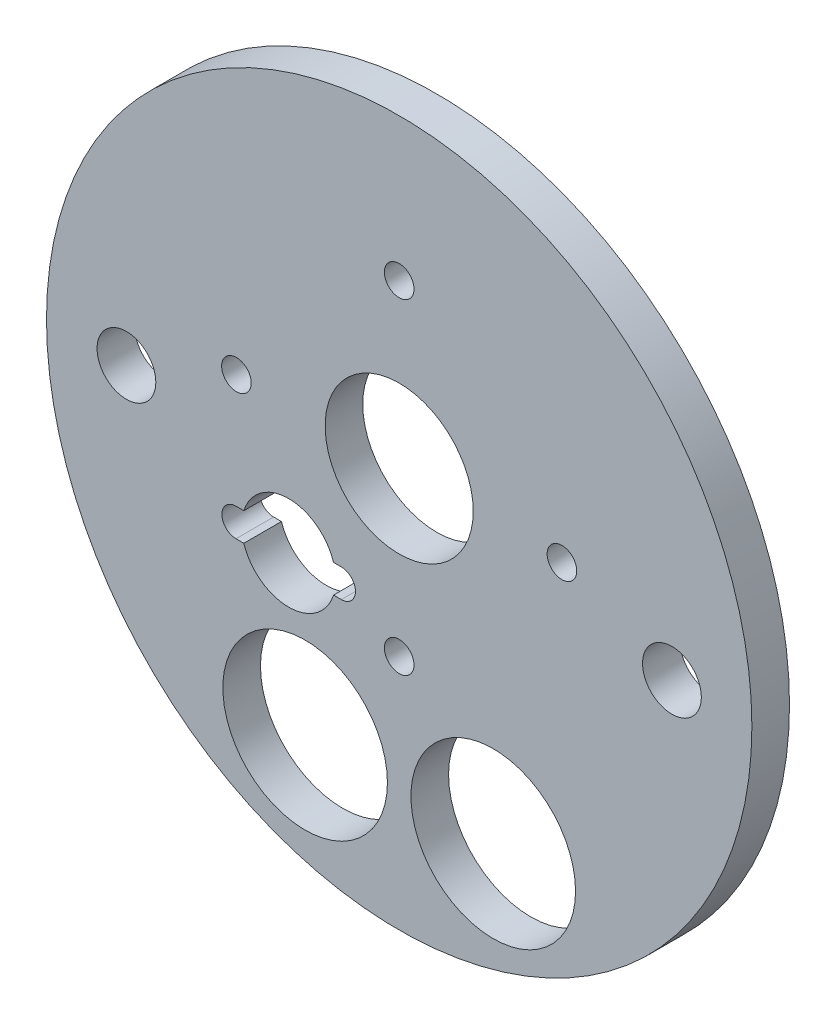
from build123d import *

# Parameters (mm, degrees)
SKETCH1_R           = 49.5046
BOSS_EXTRUDE1_DEPTH = 5.08
SKETCH2_R           = 47.625
BOSS_EXTRUDE2_DEPTH = 5.08
SKETCH3_R           = 11.1125
SKETCH3_R_2         = 3.96875
SKETCH3_R_3         = 10
SKETCH3_R_4         = 2
CUT_EXTRUDE1_DEPTH  = 11.16
SKETCH7_R           = 52.166274697
CUT_EXTRUDE4_DEPTH  = 5.08


with BuildPart() as part:
    # Sketch1 → Boss-Extrude1 (new body)
    with BuildSketch(Plane.XY):
        Circle(SKETCH1_R)
    extrude(amount=BOSS_EXTRUDE1_DEPTH)

    # Sketch2 → Boss-Extrude2 (add)
    with BuildSketch(Plane.XY.offset(5.08)):
        Circle(SKETCH2_R)
    extrude(amount=BOSS_EXTRUDE2_DEPTH)

    # Sketch3 → Cut-Extrude1 (cut, through all)
    with BuildSketch(Plane.XY.offset(10.16)):
        with Locations((-12.7, -31.166793627)):
            Circle(SKETCH3_R)
        with Locations((12.7, -31.166793627)):
            Circle(SKETCH3_R)
        with Locations((-36.83, 0)):
            Circle(SKETCH3_R_2)
        with Locations((36.83, 0)):
            Circle(SKETCH3_R_2)
        with Locations((0, 6.35)):
            Circle(SKETCH3_R_3)
        with Locations((0, 28.326878759)):
            Circle(SKETCH3_R_4)
        with Locations((21.976878759, 6.35)):
            Circle(SKETCH3_R_4)
        with Locations((0, -15.626878759)):
            Circle(SKETCH3_R_4)
        with Locations((-21.976878759, 6.35)):
            Circle(SKETCH3_R_4)
        with BuildLine():
            Line((-7.809345457, -12.873575281), (-8.863831528, -12.873575281))
            ThreePointArc((-8.863831528, -12.873575281), (-14.921345457, -17.318575281), (-20.978859386, -12.873575281))
            Line((-20.978859386, -12.873575281), (-22.033345457, -12.873575281))
            ThreePointArc((-22.033345457, -12.873575281), (-23.938345457, -10.968575281), (-22.033345457, -9.063575281))
            Line((-22.033345457, -9.063575281), (-20.978859386, -9.063575281))
            ThreePointArc((-20.978859386, -9.063575281), (-14.921345457, -4.618575281), (-8.863831528, -9.063575281))
            Line((-8.863831528, -9.063575281), (-7.809345457, -9.063575281))
            ThreePointArc((-7.809345457, -9.063575281), (-5.904345457, -10.968575281), (-7.809345457, -12.873575281))
        make_face()
    extrude(amount=-CUT_EXTRUDE1_DEPTH, mode=Mode.SUBTRACT)

    # Sketch7 → Cut-Extrude4 (cut)
    with BuildSketch(Plane(origin=(0, 0, 0), x_dir=(-1, 0, 0), z_dir=(0, 0, -1))):
        Circle(SKETCH7_R)
    extrude(amount=-CUT_EXTRUDE4_DEPTH, mode=Mode.SUBTRACT)


solid = part.part
